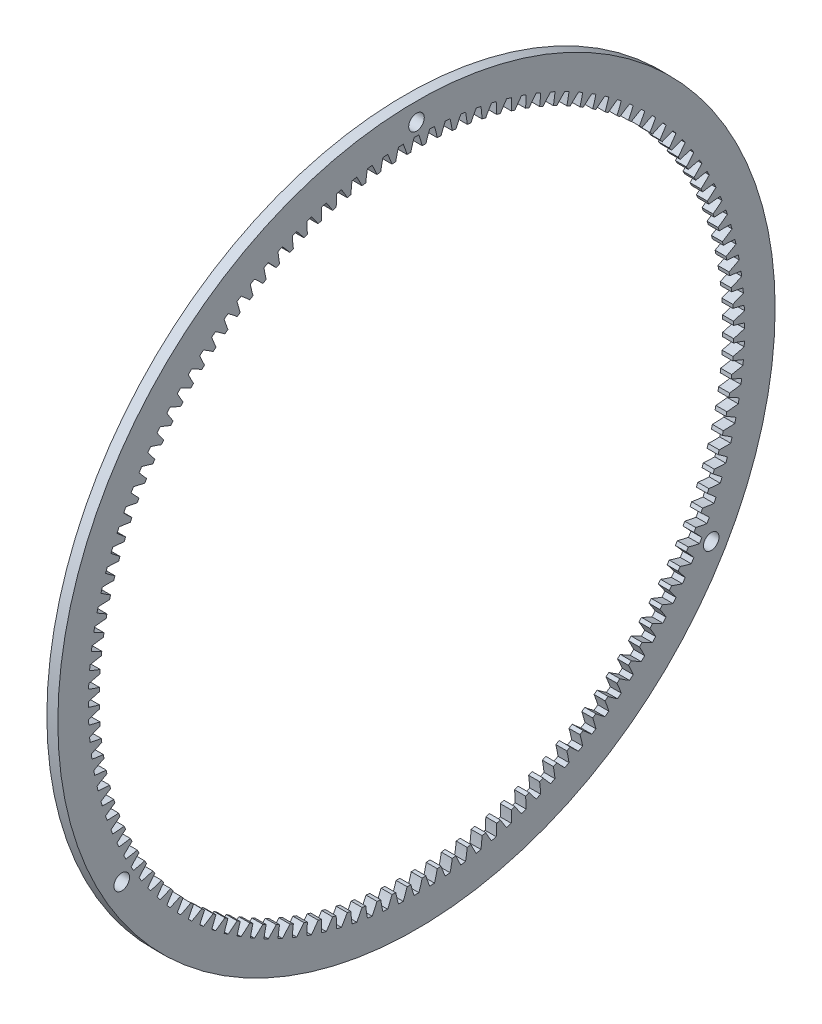
from build123d import *

# Parameters (mm, degrees)
BASPROSKE_W              = 4.7625
BASPROSKE_H              = 17.991666667
TOOTHCUT_DEPTH           = 221.067813767
TEETHCUTS_COUNT          = 132
TEETHCUTS_ANGLE          = 357.272727273
H_0_266_DIAMETER_HOLE1_D = 6.7564


with BuildPart() as part:
    # BasProSke → Base-Revolve (revolve)
    with BuildSketch(Plane(origin=(0, 0, 0), x_dir=(1, 0, 0), z_dir=(0, 1, 0))):
        with Locations((2.38125, 146.579166667)):
            Rectangle(BASPROSKE_W, BASPROSKE_H)
    revolve(axis=Axis((-10, 0, 0), (1, 0, 0)))

    # TooCutSke → ToothCut (cut, through all)
    with BuildSketch(Plane(origin=(0, 0, 0), x_dir=(0, 0, -1), z_dir=(1, 0, 0))):
        with BuildLine():
            ThreePointArc((2.463478131, 137.535872769), (1.798261095, 139.952273766), (1.046783149, 142.343254397))
            ThreePointArc((1.046783149, 142.343254397), (0, 142.347103333), (-1.046783149, 142.343254397))
            ThreePointArc((-1.046783149, 142.343254397), (-1.798261095, 139.952273766), (-2.463478131, 137.535872769))
            ThreePointArc((-2.463478131, 137.535872769), (0, 137.557933333), (2.463478131, 137.535872769))
        make_face()
    toothcut = extrude(amount=TOOTHCUT_DEPTH, mode=Mode.SUBTRACT)

    # TeethCuts: ToothCut ×132 about axis
    teethcuts_axis = Axis((-10, 0, 0), (1, 0, 0))
    for i in range(1, TEETHCUTS_COUNT):
        add(toothcut.rotate(teethcuts_axis, i * TEETHCUTS_ANGLE / (TEETHCUTS_COUNT - 1)), mode=Mode.SUBTRACT)

    # H _0.266_ Diameter Hole1 (through all)
    with Locations(Plane(origin=(4.7625, 0, 0), x_dir=(0, 0, -1), z_dir=(1, 0, 0))):
        with Locations((0, 147.6375), (-127.857825551, -73.81875), (127.857825551, -73.81875)):
            Hole(H_0_266_DIAMETER_HOLE1_D / 2)


solid = part.part
